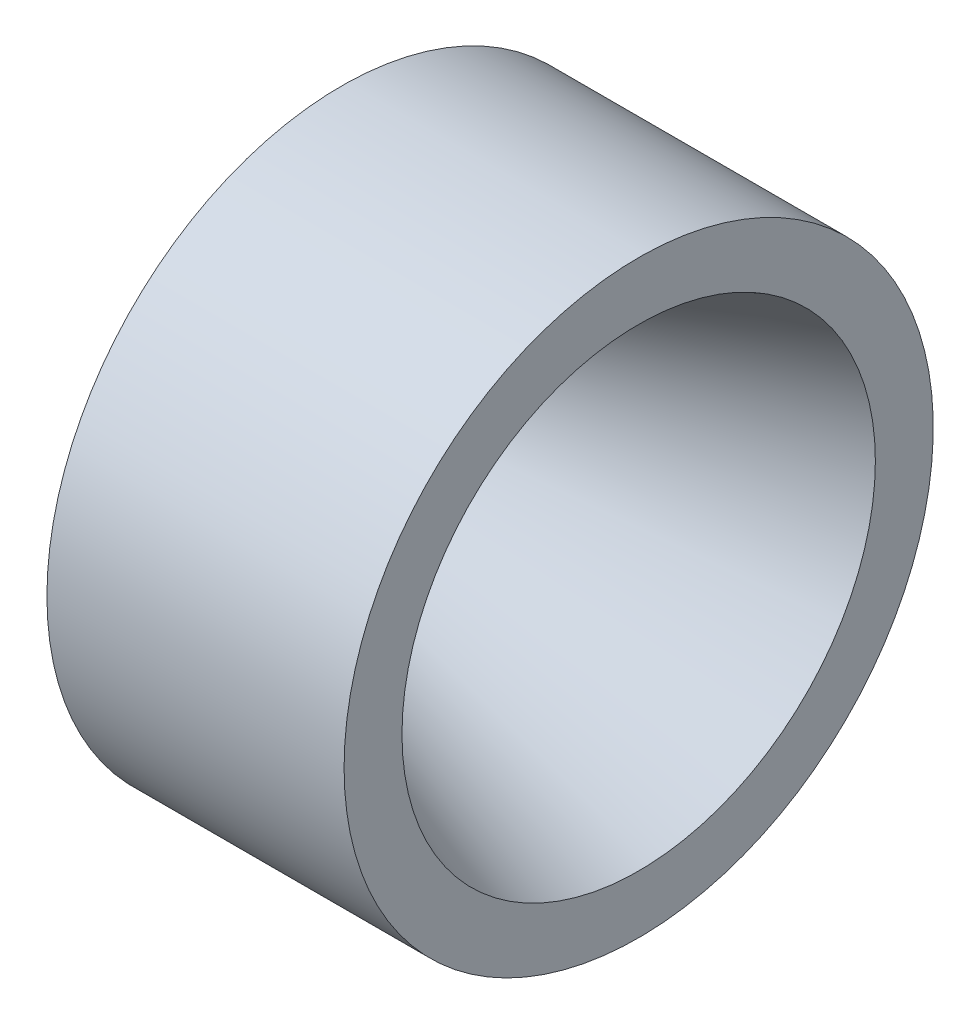
from build123d import *

# Parameters (mm, degrees)
SKETCH4_R          = 2.54
CUT_EXTRUDE1_DEPTH = 30.48
CIRPATTERN1_COUNT  = 12


with BuildPart() as part:
    # Sketch1 → Revolve1 (revolve)
    with BuildSketch(Plane.XY):
        Polygon((280.911030354, 30.48), (351.369552102, 56.124804667), (351.369552102, 69.85), (280.911030354, 69.85), (280.911030354, 50.8), align=None)
    revolve(axis=Axis((0, 0, 0), (1, 0, 0)))

    # Sketch4 → Cut-Extrude1 (cut)
    with BuildSketch(Plane.ZY.offset(-280.911030354)):
        with Locations((0, 59.69)):
            Circle(SKETCH4_R)
    cut_extrude1 = extrude(amount=-CUT_EXTRUDE1_DEPTH, mode=Mode.SUBTRACT)

    # CirPattern1: Cut-Extrude1 ×12 about axis
    cirpattern1_axis = Axis((0, 0, 0), (1, 0, 0))
    for i in range(1, CIRPATTERN1_COUNT):
        add(cut_extrude1.rotate(cirpattern1_axis, i * 360 / CIRPATTERN1_COUNT), mode=Mode.SUBTRACT)


solid = part.part
